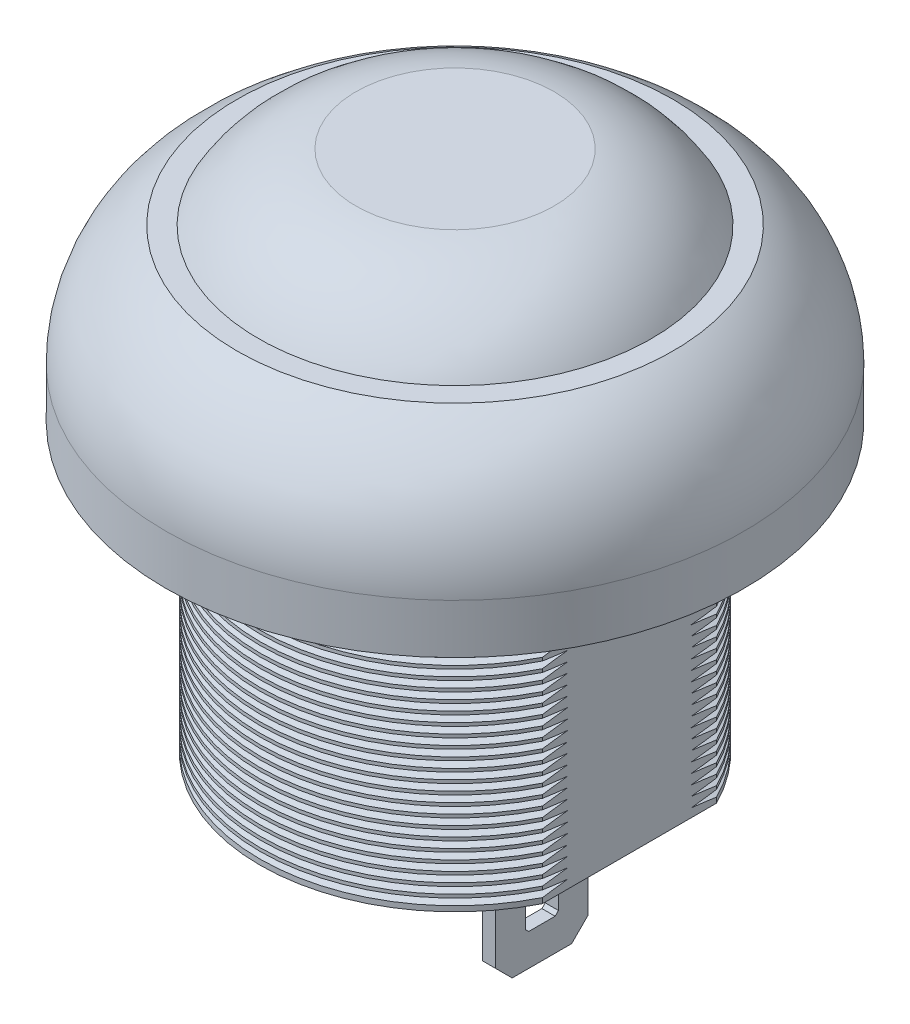
from build123d import *

# Parameters (mm, degrees)
SKETCH1_R                = 8.75
BOSS_EXTRUDE1_DEPTH      = 1.5
SKETCH7_R                = 6.61
BOSS_EXTRUDE2_DEPTH      = 1.12
SKETCH8_R                = 5.9
BOSS_EXTRUDE3_DEPTH      = 7.56
SKETCH9_R                = 4.34
BOSS_EXTRUDE4_DEPTH      = 0.7
SKETCH10_W               = 0.4
SKETCH10_H               = 3.44
BOSS_EXTRUDE5_DEPTH      = 1.4
BOSS_EXTRUDE5_DEPTH_BACK = 1.4
CHAMFER1_SIZE            = 0.5
CUT_EXTRUDE1_DEPTH       = 12.3800001
CUT_EXTRUDE2_DEPTH       = 7.56
CUT_EXTRUDE3_DEPTH       = 1.12


with BuildPart() as part:
    # Sketch1 → Boss-Extrude1 (new body)
    with BuildSketch(Plane(origin=(0, 0, 0), x_dir=(1, 0, 0), z_dir=(0, 1, 0))):
        Circle(SKETCH1_R)
    extrude(amount=BOSS_EXTRUDE1_DEPTH)

    # Sketch3 → Revolve1 (revolve)
    with BuildSketch(Plane.XY):
        with BuildLine():
            Line((-8.75, 1.5), (0, 1.5))
            Line((0, 1.5), (0, 5.15))
            Line((0, 5.15), (-6.6, 5.15))
            ThreePointArc((-6.6, 5.15), (-8.172549254, 3.618076958), (-8.75, 1.5))
        make_face()
    revolve(axis=Axis((0, 1.5, 0), (0, 1, 0)))

    # Sketch6 → Revolve2 (revolve)
    with BuildSketch(Plane.XY):
        with BuildLine():
            Line((-3, 7.15), (0, 7.15))
            Line((0, 7.15), (0, 5.15))
            Line((0, 5.15), (-5.95, 5.15))
            ThreePointArc((-5.95, 5.15), (-4.699241766, 6.480756605), (-3, 7.15))
        make_face()
    revolve(axis=Axis((0, 5.15, 0), (0, 1, 0)))

    # Sketch7 → Boss-Extrude2 (add)
    with BuildSketch(Plane.XZ):
        Circle(SKETCH7_R)
    extrude(amount=BOSS_EXTRUDE2_DEPTH)

    # Sketch8 → Boss-Extrude3 (add)
    with BuildSketch(Plane.XZ.offset(1.12)):
        Circle(SKETCH8_R)
    extrude(amount=BOSS_EXTRUDE3_DEPTH)

    # Sketch9 → Boss-Extrude4 (add)
    with BuildSketch(Plane.XZ.offset(8.68)):
        Circle(SKETCH9_R)
    extrude(amount=BOSS_EXTRUDE4_DEPTH)

    # Sketch10 → Boss-Extrude5 (add, two sides)
    with BuildSketch(Plane.XY) as boss_extrude5_sk:
        with Locations((-2.43, -11.1)):
            Rectangle(SKETCH10_W, SKETCH10_H)
        with Locations((2.43, -11.1)):
            Rectangle(SKETCH10_W, SKETCH10_H)
    extrude(amount=BOSS_EXTRUDE5_DEPTH)
    extrude(boss_extrude5_sk.sketch, amount=-BOSS_EXTRUDE5_DEPTH_BACK)

    # Chamfer1
    chamfer1_edges = [part.edges().sort_by_distance(p)[0] for p in [
        (-2.43, -12.82, -1.4),
        (-2.43, -12.82, 1.4),
        (2.43, -12.82, -1.4),
        (2.43, -12.82, 1.4),
    ]]
    chamfer(chamfer1_edges, length=CHAMFER1_SIZE)

    # Sketch11 → Cut-Extrude1 (cut, through all)
    with BuildSketch(Plane(origin=(2.63, 0, 0), x_dir=(0, 0, -1), z_dir=(1, 0, 0))):
        Polygon((0.5, -10.45), (0.4, -10.35), (-0.4, -10.35), (-0.5, -10.45), (-0.5, -11.75), (-0.4, -11.85), (0.4, -11.85), (0.5, -11.75), align=None)
    extrude(amount=-CUT_EXTRUDE1_DEPTH, mode=Mode.SUBTRACT)

    # Sketch12 → Cut-Extrude2 (cut)
    with BuildSketch(Plane.XZ.offset(8.68)):
        with BuildLine():
            Line((5.28, 2.632793194), (5.28, -2.632793194))
            ThreePointArc((5.28, -2.632793194), (5.9, 0), (5.28, 2.632793194))
        make_face()
        with BuildLine():
            Line((-5.28, 2.632793194), (-5.28, -2.632793194))
            ThreePointArc((-5.28, -2.632793194), (-5.9, 0), (-5.28, 2.632793194))
        make_face()
    extrude(amount=-CUT_EXTRUDE2_DEPTH, mode=Mode.SUBTRACT)

    # Sketch13 → Cut-Extrude3 (cut)
    with BuildSketch(Plane.XZ.offset(1.12)):
        with BuildLine():
            Line((-2.980285221, 5.9), (2.980285221, 5.9))
            ThreePointArc((2.980285221, 5.9), (0, 6.61), (-2.980285221, 5.9))
        make_face()
    extrude(amount=-CUT_EXTRUDE3_DEPTH, mode=Mode.SUBTRACT)

    # Sketch14 → Cut-Revolve1 (revolve, cut)
    with BuildSketch(Plane(origin=(0, 0, 0), x_dir=(0, 0, -1), z_dir=(1, 0, 0))):
        Polygon((-5.9, -1.12), (-5.6, -1.22), (-5.9, -1.32), align=None)
        Polygon((-5.6, -1.52), (-5.9, -1.62), (-5.9, -1.42), align=None)
        Polygon((-5.6, -1.82), (-5.9, -1.92), (-5.9, -1.72), align=None)
        Polygon((-5.6, -2.12), (-5.9, -2.22), (-5.9, -2.02), align=None)
        Polygon((-5.6, -2.42), (-5.9, -2.52), (-5.9, -2.32), align=None)
        Polygon((-5.6, -2.72), (-5.9, -2.82), (-5.9, -2.62), align=None)
        Polygon((-5.6, -3.02), (-5.9, -3.12), (-5.9, -2.92), align=None)
        Polygon((-5.6, -3.32), (-5.9, -3.42), (-5.9, -3.22), align=None)
        Polygon((-5.6, -3.62), (-5.9, -3.72), (-5.9, -3.52), align=None)
        Polygon((-5.6, -3.92), (-5.9, -4.02), (-5.9, -3.82), align=None)
        Polygon((-5.6, -4.22), (-5.9, -4.32), (-5.9, -4.12), align=None)
        Polygon((-5.6, -4.52), (-5.9, -4.62), (-5.9, -4.42), align=None)
        Polygon((-5.6, -4.82), (-5.9, -4.92), (-5.9, -4.72), align=None)
        Polygon((-5.6, -5.12), (-5.9, -5.22), (-5.9, -5.02), align=None)
        Polygon((-5.6, -5.42), (-5.9, -5.52), (-5.9, -5.32), align=None)
        Polygon((-5.6, -5.72), (-5.9, -5.82), (-5.9, -5.62), align=None)
        Polygon((-5.6, -6.02), (-5.9, -6.12), (-5.9, -5.92), align=None)
        Polygon((-5.6, -6.32), (-5.9, -6.42), (-5.9, -6.22), align=None)
        Polygon((-5.6, -6.62), (-5.9, -6.72), (-5.9, -6.52), align=None)
        Polygon((-5.6, -6.92), (-5.9, -7.02), (-5.9, -6.82), align=None)
        Polygon((-5.6, -7.22), (-5.9, -7.32), (-5.9, -7.12), align=None)
        Polygon((-5.6, -7.52), (-5.9, -7.62), (-5.9, -7.42), align=None)
        Polygon((-5.6, -7.82), (-5.9, -7.92), (-5.9, -7.72), align=None)
        Polygon((-5.6, -8.12), (-5.9, -8.22), (-5.9, -8.02), align=None)
        Polygon((-5.6, -8.42), (-5.9, -8.52), (-5.9, -8.32), align=None)
    revolve(axis=Axis((0, 0, 0), (0, -1, 0)), mode=Mode.SUBTRACT)


solid = part.part
